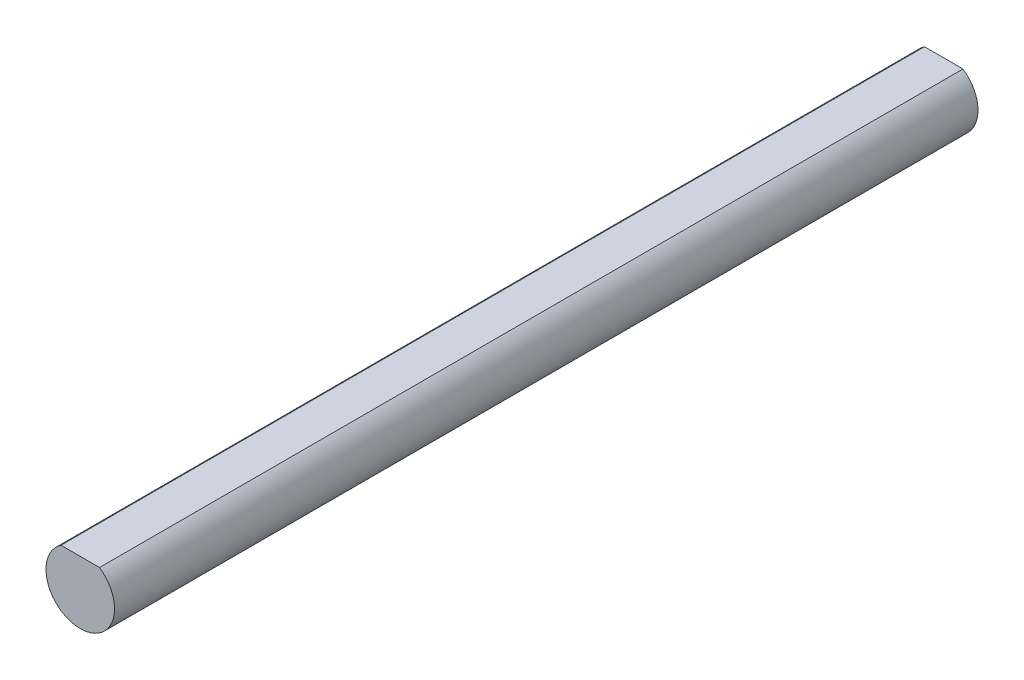
from build123d import *

# Parameters (mm, degrees)
BOSS_EXTRUDE1_DEPTH = 80


with BuildPart() as part:
    # Sketch1 → Boss-Extrude1 (new body)
    with BuildSketch(Plane.XY):
        with BuildLine():
            Line((-1.78605711, 2.625), (1.78605711, 2.625))
            ThreePointArc((1.78605711, 2.625), (0, -3.175), (-1.78605711, 2.625))
        make_face()
    extrude(amount=BOSS_EXTRUDE1_DEPTH)


solid = part.part
